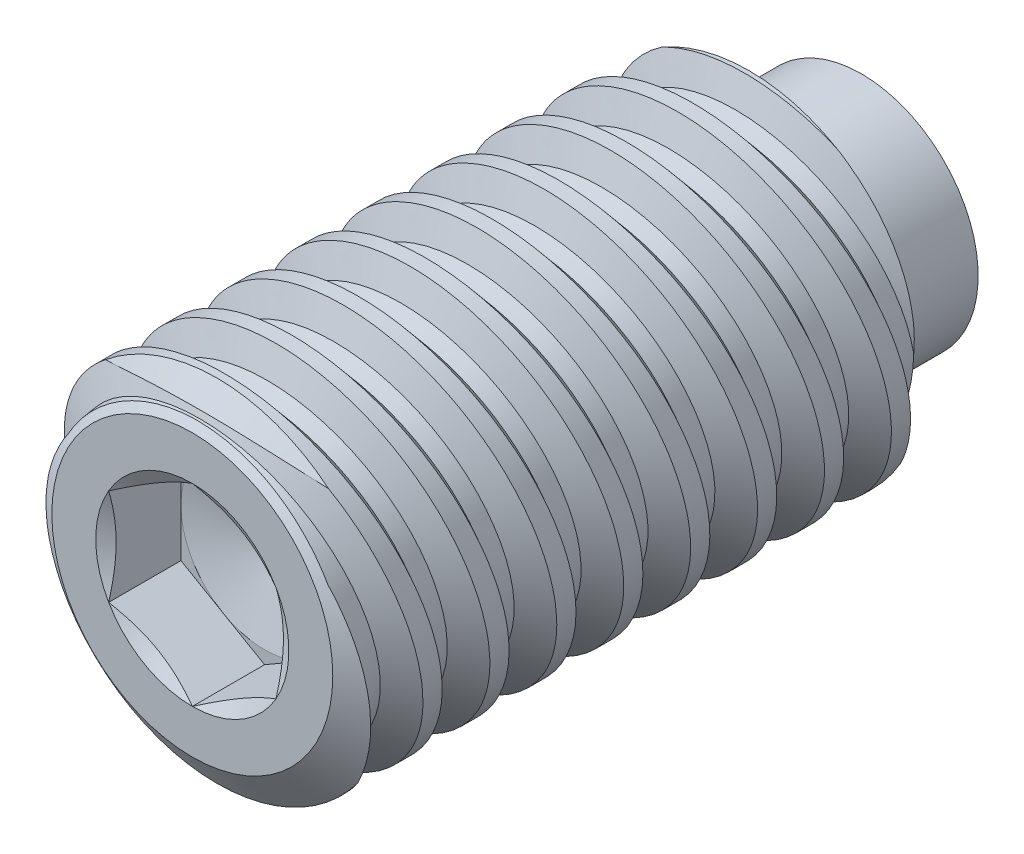
from build123d import *

# Parameters (mm, degrees)
LPATTERN1_COUNT      = 9
LPATTERN1_PITCH      = 0.79375
LPATTERN1_COUNT_DIR2 = 2
LPATTERN1_PITCH_DIR2 = 0.79375
CUT_EXTRUDE10_DEPTH  = 0.85725


with BuildPart() as part:
    # Sketch22 → Revolve1 (revolve)
    with BuildSketch(Plane(origin=(0, 0, 0), x_dir=(0, 0, -1), z_dir=(1, 0, 0))):
        Polygon((-3.96875, 0), (-3.96875, 1.66624), (-3.677071548, 2.0828), (2.636048972, 2.0828), (2.87655, 1.66624), (2.87655, 1.3843), (3.96875, 1.3843), (3.96875, 0), align=None)
    revolve(axis=Axis((0, 0, -4.477275863), (0, 0, 1)))

    # Sketch6 → Cut-Revolve8 (revolve, cut)
    with BuildSketch(Plane(origin=(0, 0, 0), x_dir=(0, 0, -1), z_dir=(1, 0, 0))):
        Polygon((2.47280471, 1.762908932), (2.277874503, 1.725765218), (1.953793244, 2.101371857), (2.636048972, 2.231374854), align=None)
    cut_revolve8 = revolve(axis=Axis((0, 0.162231854, -3.559113678), (0, -0.1871809179215644, 0.9823254572523511)), mode=Mode.SUBTRACT)

    # LPattern1: Cut-Revolve8 9 × 2
    with Locations(*[Vector(0, 0, 1) * (i * LPATTERN1_PITCH) + Vector(0, 0, 1) * (j * LPATTERN1_PITCH_DIR2) for i in range(LPATTERN1_COUNT) for j in range(LPATTERN1_COUNT_DIR2) if (i, j) != (0, 0)]):
        add(cut_revolve8, mode=Mode.SUBTRACT)

    # Sketch23 → Cut-Extrude10 (cut)
    with BuildSketch(Plane.XY.offset(3.96875)):
        Polygon((0, 1.14567944), (-0.9921875, 0.57283972), (-0.9921875, -0.57283972), (0, -1.14567944), (0.9921875, -0.57283972), (0.9921875, 0.57283972), align=None)
    extrude(amount=-CUT_EXTRUDE10_DEPTH, mode=Mode.SUBTRACT)

    # Cut-Extrude11 cone 1 section (through the dimple's axis) → Cut-Extrude11 (revolve, cut)
    with BuildSketch(Plane(origin=(0, 0, 3.96875), x_dir=(0, -1, 0), z_dir=(1, 0, 0))):
        Polygon((0, 0), (1.14567944, 0), (0, 0.661458333), align=None)
    revolve(axis=Axis((0, 0, 3.96875), (0, 0, -1)), mode=Mode.SUBTRACT)

    # Cut-Extrude12 cone 1 section (through the dimple's axis) → Cut-Extrude12 (revolve, cut)
    with BuildSketch(Plane(origin=(0, 0, 3.1115), x_dir=(0, -1, 0), z_dir=(1, 0, 0))):
        Polygon((0, 0), (0.9921875, 0), (0, 0.265855839), align=None)
    revolve(axis=Axis((0, 0, 3.1115), (0, 0, -1)), mode=Mode.SUBTRACT)


solid = part.part
